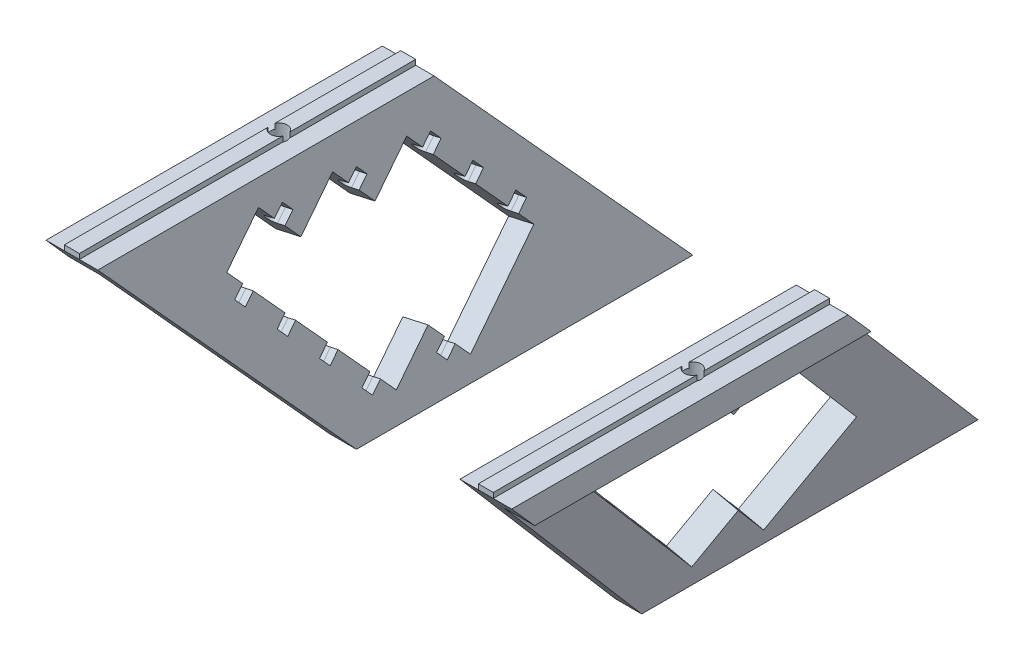
from build123d import *

# Parameters (mm, degrees)
MAIN_DEPTH               = 52.5
SKETCH3_R                = 1.6
MAKERBEAMFIXHOLES_DEPTH  = 47
SIDECUT_DEPTH            = 21
SIDECUT_DEPTH_BACK       = 1
CENTRALCUT_DEPTH         = 10
ROLLERSUPPORTHOLES_DEPTH = 2.5
LPATTERN1_COUNT          = 4
LPATTERN1_PITCH          = 10
CUT_EXTRUDE1_DEPTH       = 25
CUT_EXTRUDE2_DEPTH       = 35
CUT_EXTRUDE3_DEPTH       = 35
CUT_EXTRUDE4_DEPTH       = 2.5
SKETCH10_R               = 4.25
CUT_EXTRUDE5_DEPTH       = 5


with BuildPart() as part:
    # Sketch1 → Main (new body, symmetric)
    with BuildSketch(Plane.XY):
        Polygon((20, 45), (20, 40), (14.010858032, 40), (5.121969143, 0), (0, 0), (10, 45), (13.55, 45), (13.55, 46), (16.45, 46), (16.45, 45), align=None)
    extrude(amount=MAIN_DEPTH, both=True)

    # Sketch3 → MakerBeamFixHoles (cut, through all)
    with BuildSketch(Plane(origin=(0, 46, 0), x_dir=(1, 0, 0), z_dir=(0, 1, 0))):
        with Locations((15, -12.5)):
            Circle(SKETCH3_R)
    extrude(amount=-MAKERBEAMFIXHOLES_DEPTH, mode=Mode.SUBTRACT)

    # Sketch2 → SideCut (cut, two sides)
    with BuildSketch(Plane(origin=(0, 40.615528128, 0), x_dir=(0, 0, 1), z_dir=(1, 0, 0))) as sidecut_sk:
        Polygon((-52.5, 40.615528128), (-12.5, -4.384471872), (-12.5, -5.384471872), (-52.5, -5.384471872), align=None)
        Polygon((52.5, -4.384471872), (52.5, 40.615528128), (12.5, 40.615528128), align=None)
    extrude(amount=SIDECUT_DEPTH, mode=Mode.SUBTRACT)
    extrude(sidecut_sk.sketch, amount=-SIDECUT_DEPTH_BACK, mode=Mode.SUBTRACT)

    # Sketch5 → CentralCut (cut)
    with BuildSketch(Plane(origin=(0, 0, 0), x_dir=(0, 0, 1), z_dir=(-0.97618706, 0.216930458, 0))):
        Polygon((22.349889157, 41.867825412), (15.796033792, 34.3148803), (8.24308868, 40.868735664), (1.689233316, 33.315790552), (-5.863711796, 39.869645916), (-25.525277888, 17.21081058), (-10.419387664, 4.103099851), (-3.8655323, 11.656044963), (3.687412812, 5.102189599), (29.902834269, 35.313970048), align=None)
    extrude(amount=-CENTRALCUT_DEPTH, mode=Mode.SUBTRACT)

    # Sketch4 → RollerSupportHoles (cut)
    with BuildSketch(Plane(origin=(0.079448965, 7.857631633, 5.930962816), x_dir=(-0.989841813, 0.091892801, -0.108484557), z_dir=(-0.142173084, -0.63977888, 0.755294511))):
        with BuildLine():
            Line((-6.624479528, -29.639079578), (-7.038299145, -32.104592369))
            Line((-7.038299145, -32.104592369), (-8.51760682, -31.856300599))
            ThreePointArc((-8.51760682, -31.856300599), (-9.543453407, -30.416634395), (-8.103787203, -29.390787808))
            Line((-8.103787203, -29.390787808), (-6.624479528, -29.639079578))
        make_face()
    rollersupportholes = extrude(amount=ROLLERSUPPORTHOLES_DEPTH, mode=Mode.SUBTRACT)

    # LPattern1: RollerSupportHoles ×4
    with Locations(*[Vector(-0.163846384, -0.737308728, -0.655385536) * (i * LPATTERN1_PITCH) for i in range(1, LPATTERN1_COUNT)]):
        add(rollersupportholes, mode=Mode.SUBTRACT)

    # Sketch6 → Cut-Extrude1 (cut)
    with BuildSketch(Plane(origin=(-0.275983746, -1.241926856, 1.466163649), x_dir=(-0.989841813, 0.091892801, -0.108484557), z_dir=(0.142173084, 0.63977888, -0.755294511))):
        with BuildLine():
            Line((-5.383020676, 32.071718622), (-4.969201058, 29.60620583))
            Line((-4.969201058, 29.60620583), (-6.448508733, 29.35791406))
            ThreePointArc((-6.448508733, 29.35791406), (-7.888174937, 30.383760647), (-6.86232835, 31.823426851))
            Line((-6.86232835, 31.823426851), (-5.383020676, 32.071718622))
        make_face()
    extrude(amount=CUT_EXTRUDE1_DEPTH, mode=Mode.SUBTRACT)

    # Mirror5: RollerSupportHoles across plane
    add(rollersupportholes.mirror(Plane(origin=(0.790314388, 3.556414745, -4.198545185), x_dir=(0.163846384, 0.737308728, 0.655385536), z_dir=(0.142173084, 0.63977888, -0.755294511))), mode=Mode.SUBTRACT)

    # Sketch7 → Cut-Extrude2 (cut)
    with BuildSketch(Plane(origin=(-0.275983746, -1.241926856, 1.466163649), x_dir=(-0.989841813, 0.091892801, -0.108484557), z_dir=(0.142173084, 0.63977888, -0.755294511))):
        with BuildLine():
            Line((-4.793230263, 19.495862895), (-3.313922588, 19.744154665))
            Line((-3.313922588, 19.744154665), (-3.727742206, 22.209667456))
            Line((-3.727742206, 22.209667456), (-5.20704988, 21.961375686))
            ThreePointArc((-5.20704988, 21.961375686), (-6.232896467, 20.521709481), (-4.793230263, 19.495862895))
        make_face()
    extrude(amount=CUT_EXTRUDE2_DEPTH, mode=Mode.SUBTRACT)

    # Sketch8 → Cut-Extrude3 (cut)
    with BuildSketch(Plane(origin=(-0.275983746, -1.241926856, 1.466163649), x_dir=(-0.989841813, 0.091892801, -0.108484557), z_dir=(0.142173084, 0.63977888, -0.755294511))):
        with BuildLine():
            Line((-3.137951793, 9.633811729), (-1.658644118, 9.8821035))
            Line((-1.658644118, 9.8821035), (-2.072463736, 12.347616291))
            Line((-2.072463736, 12.347616291), (-3.551771411, 12.099324521))
            ThreePointArc((-3.551771411, 12.099324521), (-4.577617998, 10.659658316), (-3.137951793, 9.633811729))
        make_face()
    extrude(amount=CUT_EXTRUDE3_DEPTH, mode=Mode.SUBTRACT)

    # Sketch9 → Cut-Extrude4 (cut)
    with BuildSketch(Plane(origin=(4.344641499, 19.550886747, -23.080907965), x_dir=(0.989841813, -0.091892801, 0.108484557), z_dir=(-0.142173084, -0.63977888, 0.755294511))):
        with BuildLine():
            Line((-0.02209942, -0.131667038), (1.47790058, -0.383431875))
            ThreePointArc((1.47790058, -0.383431875), (2.937704611, 0.656764094), (1.897508642, 2.116568125))
            Line((1.897508642, 2.116568125), (0.397508642, 2.368332962))
            Line((0.397508642, 2.368332962), (-0.02209942, -0.131667038))
        make_face()
    cut_extrude4 = extrude(amount=-CUT_EXTRUDE4_DEPTH, mode=Mode.SUBTRACT)

    # Sketch10 → Cut-Extrude5 (cut)
    with BuildSketch(Plane.XZ.offset(-40)):
        with Locations((15, 12.5)):
            Circle(SKETCH10_R)
    extrude(amount=CUT_EXTRUDE5_DEPTH, mode=Mode.SUBTRACT)

    # Mirror6: Cut-Extrude4 across plane
    add(cut_extrude4.mirror(Plane(origin=(18.62754414, 37.726226343, 8.24308868), x_dir=(0.163846384, 0.737308728, 0.655385536), z_dir=(0.142173084, 0.63977888, -0.755294511))), mode=Mode.SUBTRACT)


with BuildPart() as body_2:
    # Mirror4: mirrored copy
    add(part.part.mirror(Plane(origin=(-25, 0, 0), x_dir=(0, 0, 1), z_dir=(1, 0, 0))))


solid = Compound([part.part, body_2.part])
